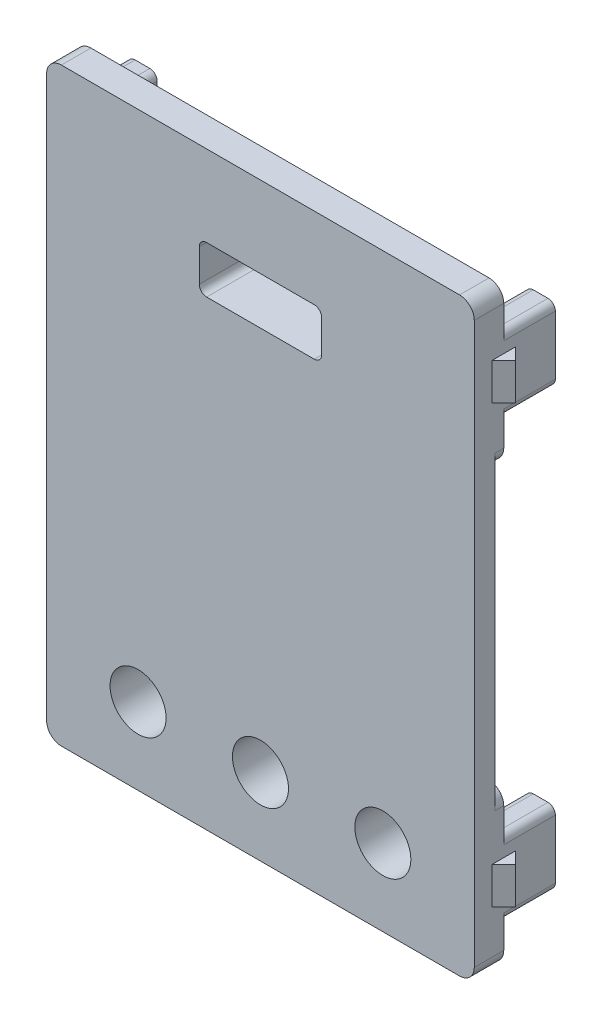
from build123d import *

# Parameters (mm, degrees)
SKETCH_1_W          = 29
SKETCH_1_H          = 40
EXTRUDE_1_DEPTH     = 2
SKETCH_2_W          = 2
SKETCH_2_H          = 5
EXTRUDE_2_DEPTH     = 3.5
SKETCH_3_W          = 8.3
SKETCH_3_H          = 3.2
CUT_EXTRUDE_1_DEPTH = 50.71166865
SKETCH_4_R          = 1.9
CUT_EXTRUDE_2_DEPTH = 50.71166865
SKETCH_5_W          = 10.7
SKETCH_5_H          = 5.6
SKETCH_5_W_2        = 8.3
SKETCH_5_H_2        = 3.2
EXTRUDE_3_DEPTH     = 2
SKETCH_6_R          = 3.1
SKETCH_6_R_2        = 1.9
EXTRUDE_4_DEPTH     = 1
EXTRUDE_5_DEPTH     = 1.25
FILLET_1_R          = 0.5
FILLET_2_R          = 0.5
CHAMFER_1_SIZE      = 0.2
CHAMFER_2_SIZE      = 0.5
FILLET_3_R          = 1
FILLET_4_R          = 1
SKETCH_9_W          = 29
SKETCH_9_H          = 19
CUT_EXTRUDE_3_DEPTH = 0.6
FILLET_5_R          = 1


with BuildPart() as part:
    # 草图1 → 凸台-拉伸1 (new body)
    with BuildSketch(Plane.XY):
        with Locations((14.5, 20)):
            Rectangle(SKETCH_1_W, SKETCH_1_H)
    extrude(amount=EXTRUDE_1_DEPTH)

    # 草图2 → 凸台-拉伸2 (add)
    with BuildSketch(Plane(origin=(0, 0, 0), x_dir=(-1, 0, 0), z_dir=(0, 0, -1))):
        with Locations((-1, 34.8)):
            Rectangle(SKETCH_2_W, SKETCH_2_H)
        with Locations((-28, 34.8)):
            Rectangle(SKETCH_2_W, SKETCH_2_H)
        with Locations((-1, 5.2)):
            Rectangle(SKETCH_2_W, SKETCH_2_H)
        with Locations((-28, 5.2)):
            Rectangle(SKETCH_2_W, SKETCH_2_H)
    extrude(amount=EXTRUDE_2_DEPTH)

    # 草图3 → 切除-拉伸1 (cut, through all)
    with BuildSketch(Plane.XY.offset(2)):
        with Locations((14.5, 32.9)):
            Rectangle(SKETCH_3_W, SKETCH_3_H)
    extrude(amount=-CUT_EXTRUDE_1_DEPTH, mode=Mode.SUBTRACT)

    # 草图4 → 切除-拉伸2 (cut, through all)
    with BuildSketch(Plane.XY.offset(2)):
        with Locations((14.5, 5.2)):
            Circle(SKETCH_4_R)
        with Locations((6.2, 5.2)):
            Circle(SKETCH_4_R)
        with Locations((22.8, 5.2)):
            Circle(SKETCH_4_R)
    extrude(amount=-CUT_EXTRUDE_2_DEPTH, mode=Mode.SUBTRACT)

    # 草图5 → 凸台-拉伸3 (add)
    with BuildSketch(Plane(origin=(0, 0, 0), x_dir=(-1, 0, 0), z_dir=(0, 0, -1))):
        with Locations((-14.5, 32.9)):
            Rectangle(SKETCH_5_W, SKETCH_5_H)
        with Locations((-14.5, 32.9)):
            Rectangle(SKETCH_5_W_2, SKETCH_5_H_2, mode=Mode.SUBTRACT)
    extrude(amount=EXTRUDE_3_DEPTH)

    # 草图6 → 凸台-拉伸4 (add)
    with BuildSketch(Plane(origin=(0, 0, 0), x_dir=(-1, 0, 0), z_dir=(0, 0, -1))):
        with Locations((-22.8, 5.2)):
            Circle(SKETCH_6_R)
        with Locations(Location((-22.8, 5.2, 0), (0, 0, 180))):
            Circle(SKETCH_6_R_2, mode=Mode.SUBTRACT)
        with Locations((-14.5, 5.2)):
            Circle(SKETCH_6_R)
        with Locations(Location((-14.5, 5.2, 0), (0, 0, 180))):
            Circle(SKETCH_6_R_2, mode=Mode.SUBTRACT)
        with Locations((-6.2, 5.2)):
            Circle(SKETCH_6_R)
        with Locations(Location((-6.2, 5.2, 0), (0, 0, 180))):
            Circle(SKETCH_6_R_2, mode=Mode.SUBTRACT)
    extrude(amount=EXTRUDE_4_DEPTH)

    # 草图10 → 凸台-拉伸5 (add, symmetric)
    with BuildSketch(Plane(origin=(0, 34.8, 0), x_dir=(-1, 0, 0), z_dir=(0, -1, 0))):
        Polygon((-29, 0.8), (-29.8, 0), (-29, -0.8), align=None)
        Polygon((0, -0.8), (0, 0.8), (0.8, 0), align=None)
    extrude_5 = extrude(amount=EXTRUDE_5_DEPTH, both=True)

    # 镜向1: 凸台-拉伸5 across plane
    add(extrude_5.mirror(Plane(origin=(0, 20, 0), x_dir=(0, 0, 1), z_dir=(0, -1, 0))))

    # 圆角1
    fillet_1_edges = [part.edges().sort_by_distance(p)[0] for p in [
        (29, 37.3, -1.75),
        (29, 32.3, -1.75),
        (27, 32.3, -1.75),
        (27, 37.3, -1.75),
        (0, 37.3, -1.75),
        (2, 37.3, -1.75),
        (2, 32.3, -1.75),
        (0, 32.3, -1.75),
        (0, 2.7, -1.75),
        (0, 7.7, -1.75),
        (2, 7.7, -1.75),
        (2, 2.7, -1.75),
        (29, 2.7, -1.75),
        (27, 2.7, -1.75),
        (27, 7.7, -1.75),
        (29, 7.7, -1.75),
    ]]
    fillet(fillet_1_edges, radius=FILLET_1_R)

    # 圆角2
    fillet_2_edges = [part.edges().sort_by_distance(p)[0] for p in [
        (18.65, 34.5, 0),
        (18.65, 31.3, 0),
        (10.35, 31.3, 0),
        (10.35, 34.5, 0),
    ]]
    fillet(fillet_2_edges, radius=FILLET_2_R)

    # 倒角1
    chamfer_1_edges = [part.edges().sort_by_distance(p)[0] for p in [
        (20.9, 5.2, -1),
        (12.6, 5.2, -1),
        (4.3, 5.2, -1),
    ]]
    chamfer(chamfer_1_edges, length=CHAMFER_1_SIZE)

    # 倒角2
    chamfer_2_edges = [part.edges().sort_by_distance(p)[0] for p in [
        (18.65, 32.9, -2),
        (14.5, 31.3, -2),
        (14.5, 34.5, -2),
        (10.35, 32.9, -2),
        (18.503553391, 31.446446609, -2),
        (18.503553391, 34.353553391, -2),
        (10.496446609, 31.446446609, -2),
        (10.496446609, 34.353553391, -2),
    ]]
    chamfer(chamfer_2_edges, length=CHAMFER_2_SIZE)

    # 圆角3
    fillet_3_edges = [part.edges().sort_by_distance(p)[0] for p in [
        (0, 40, 1),
        (29, 40, 1),
        (29, 0, 1),
        (0, 0, 1),
    ]]
    fillet(fillet_3_edges, radius=FILLET_3_R)

    # 圆角4
    fillet_4_edges = [part.edges().sort_by_distance(p)[0] for p in [
        (19.85, 30.1, -1),
        (9.15, 30.1, -1),
        (9.15, 35.7, -1),
        (19.85, 35.7, -1),
    ]]
    fillet(fillet_4_edges, radius=FILLET_4_R)

    # 草图9 → 切除-拉伸3 (cut)
    with BuildSketch(Plane(origin=(0, 0, 0), x_dir=(-1, 0, 0), z_dir=(0, 0, -1))):
        with Locations((-14.5, 20)):
            Rectangle(SKETCH_9_W, SKETCH_9_H)
    extrude(amount=-CUT_EXTRUDE_3_DEPTH, mode=Mode.SUBTRACT)

    # 圆角5
    fillet_5_edges = [part.edges().sort_by_distance(p)[0] for p in [
        (29, 10.5, 0.3),
        (29, 29.5, 0.3),
        (0, 29.5, 0.3),
        (0, 10.5, 0.3),
    ]]
    fillet(fillet_5_edges, radius=FILLET_5_R)


solid = part.part
